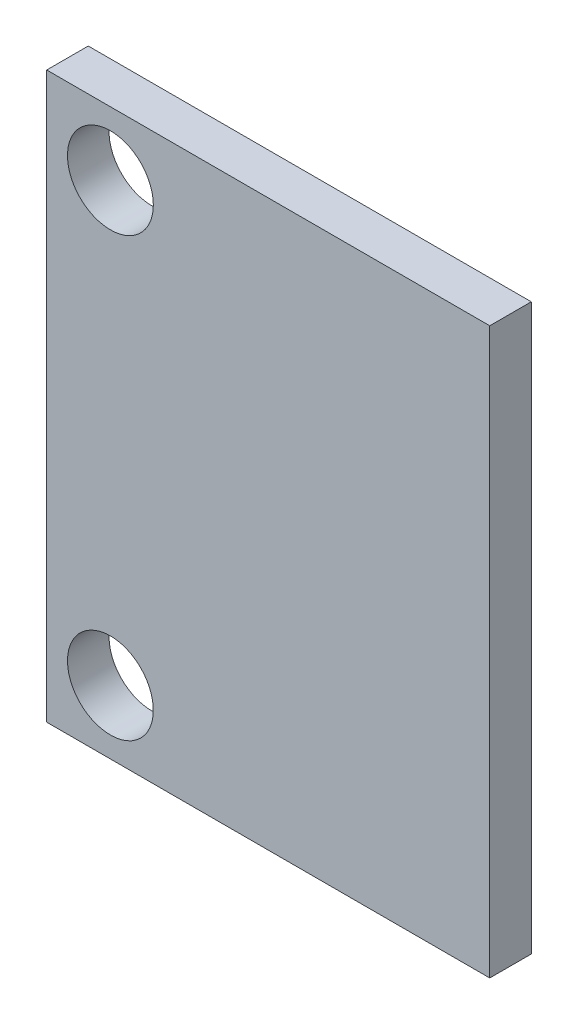
from build123d import *

# Parameters (mm, degrees)
SKETCH1_W           = 16
SKETCH1_H           = 20.4
SKETCH1_R           = 1.55
BOSS_EXTRUDE1_DEPTH = 1.5


with BuildPart() as part:
    # Sketch1 → Boss-Extrude1 (new body)
    with BuildSketch(Plane.XY):
        Rectangle(SKETCH1_W, SKETCH1_H)
        with Locations((-5.7, 7.9)):
            Circle(SKETCH1_R, mode=Mode.SUBTRACT)
        with Locations((-5.7, -7.9)):
            Circle(SKETCH1_R, mode=Mode.SUBTRACT)
    extrude(amount=BOSS_EXTRUDE1_DEPTH)


solid = part.part
